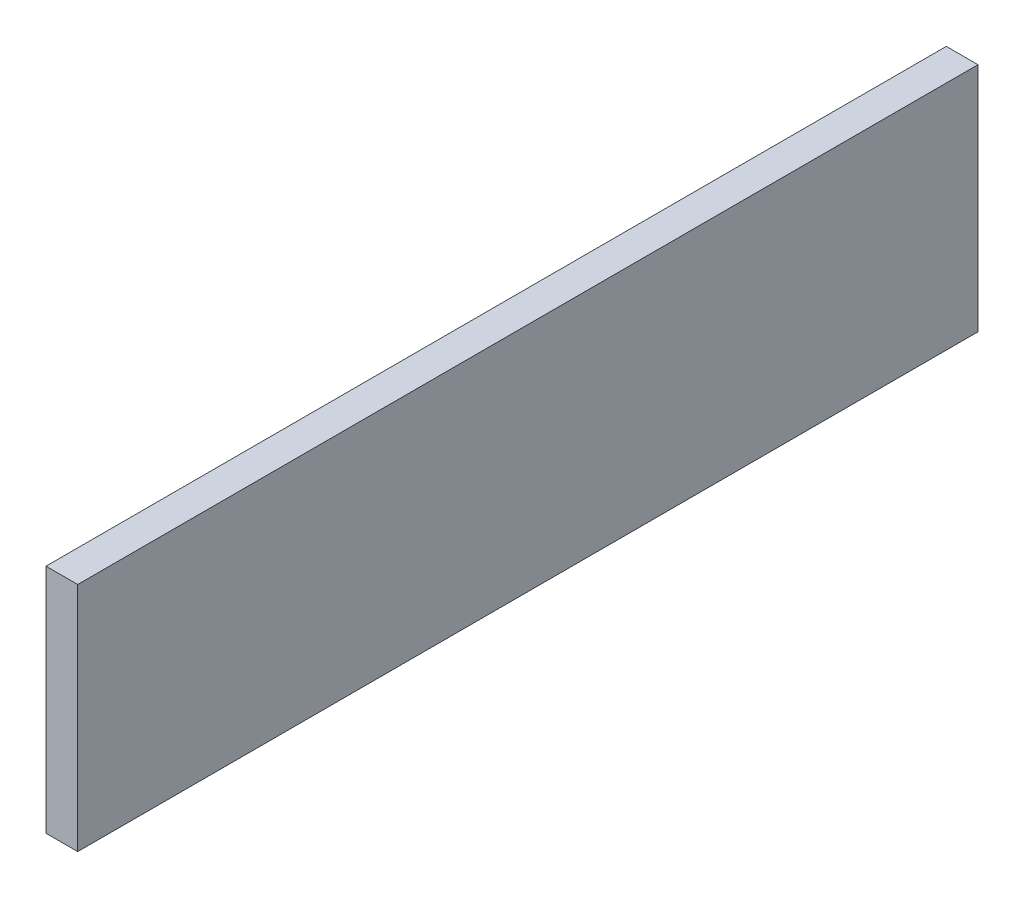
from build123d import *

# Parameters (mm, degrees)
SKETCH1_W           = 3.175
SKETCH1_H           = 23.17
BOSS_EXTRUDE1_DEPTH = 90.17


with BuildPart() as part:
    # Sketch1 → Boss-Extrude1 (new body)
    with BuildSketch(Plane.XY):
        Rectangle(SKETCH1_W, SKETCH1_H)
    extrude(amount=BOSS_EXTRUDE1_DEPTH)


solid = part.part
